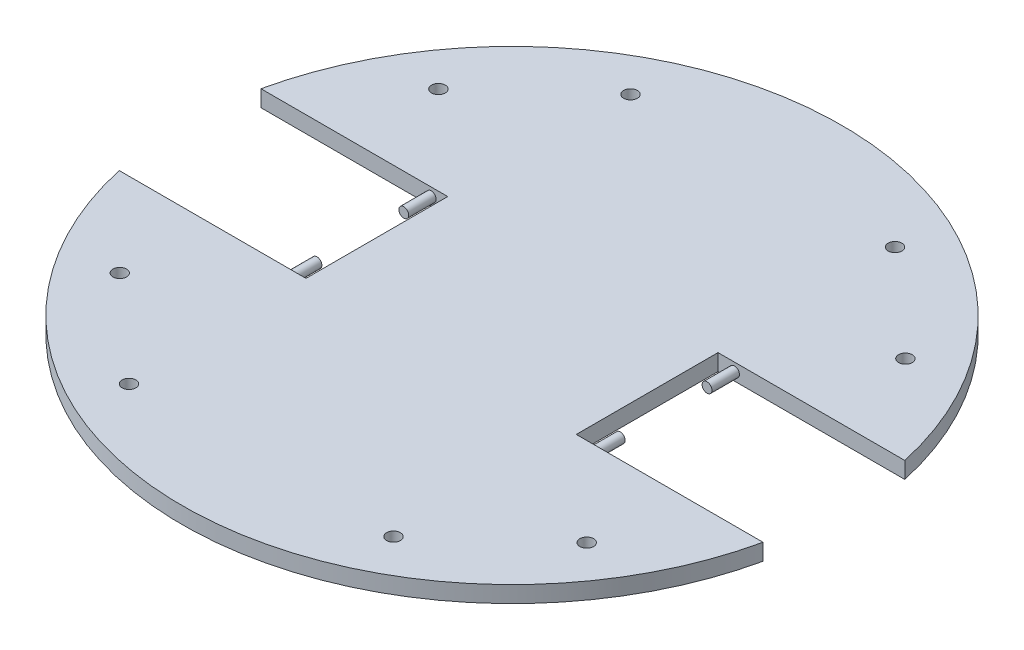
from build123d import *

# Parameters (mm, degrees)
SKETCH1_R           = 60
BOSS_EXTRUDE1_DEPTH = 3
SKETCH2_R           = 1.25
CUT_EXTRUDE1_DEPTH  = 4
CUT_EXTRUDE9_DEPTH  = 4
SKETCH5_R           = 0.9
BOSS_EXTRUDE2_DEPTH = 5
SKETCH7_R           = 0.9
BOSS_EXTRUDE3_DEPTH = 5
SKETCH8_R           = 0.9
BOSS_EXTRUDE4_DEPTH = 5
SKETCH9_R           = 0.9
BOSS_EXTRUDE5_DEPTH = 5


with BuildPart() as part:
    # Sketch1 → Boss-Extrude1 (new body)
    with BuildSketch(Plane(origin=(0, 0, 0), x_dir=(1, 0, 0), z_dir=(0, 1, 0))):
        Circle(SKETCH1_R)
    extrude(amount=BOSS_EXTRUDE1_DEPTH)

    # Sketch2 → Cut-Extrude1 (cut, through all)
    with BuildSketch(Plane(origin=(0, 3, 0), x_dir=(1, 0, 0), z_dir=(0, 1, 0))):
        with Locations((-42.393550358, 29.002085895)):
            Circle(SKETCH2_R)
        with Locations((42.606449642, 29.002085895)):
            Circle(SKETCH2_R)
        with Locations((42.606449642, -29.002085895)):
            Circle(SKETCH2_R)
        with Locations((-42.393550358, -29.002085895)):
            Circle(SKETCH2_R)
        with Locations((-24.073102507, 45.644631202)):
            Circle(SKETCH2_R)
        with Locations((24.073102507, 45.644631202)):
            Circle(SKETCH2_R)
        with Locations((24.073102507, -45.644631202)):
            Circle(SKETCH2_R)
        with Locations((-24.073102507, -45.644631202)):
            Circle(SKETCH2_R)
    extrude(amount=-CUT_EXTRUDE1_DEPTH, mode=Mode.SUBTRACT)

    # Sketch4 → Cut-Extrude9 (cut, through all)
    with BuildSketch(Plane(origin=(0, 3, 0), x_dir=(1, 0, 0), z_dir=(0, 1, 0))):
        with BuildLine():
            Line((-24.6, 12.9), (-58.596842918, 12.9))
            ThreePointArc((-58.596842918, 12.9), (-60, 0), (-58.596842918, -12.9))
            Line((-58.596842918, -12.9), (-24.6, -12.9))
            Line((-24.6, -12.9), (-24.6, 12.9))
        make_face()
        with BuildLine():
            Line((58.596842918, 12.9), (24.6, 12.9))
            Line((24.6, 12.9), (24.6, 0))
            Line((24.6, 0), (60, 0))
            ThreePointArc((60, 0), (59.648179248, 6.488043808), (58.596842918, 12.9))
        make_face()
        with BuildLine():
            Line((60, 0), (24.6, 0))
            Line((24.6, 0), (24.6, -12.9))
            Line((24.6, -12.9), (58.596842918, -12.9))
            ThreePointArc((58.596842918, -12.9), (59.648179248, -6.488043808), (60, 0))
        make_face()
    extrude(amount=-CUT_EXTRUDE9_DEPTH, mode=Mode.SUBTRACT)

    # Sketch5 → Boss-Extrude2 (add)
    with BuildSketch(Plane.XY.offset(-12.9)):
        with Locations((27.6, 1.5)):
            Circle(SKETCH5_R)
    extrude(amount=BOSS_EXTRUDE2_DEPTH)

    # Sketch7 → Boss-Extrude3 (add)
    with BuildSketch(Plane(origin=(0, 0, 12.9), x_dir=(-1, 0, 0), z_dir=(0, 0, -1))):
        with Locations((-27.6, 1.5)):
            Circle(SKETCH7_R)
    extrude(amount=BOSS_EXTRUDE3_DEPTH)

    # Sketch8 → Boss-Extrude4 (add)
    with BuildSketch(Plane.XY.offset(-12.9)):
        with Locations((-27.6, 1.5)):
            Circle(SKETCH8_R)
    extrude(amount=BOSS_EXTRUDE4_DEPTH)

    # Sketch9 → Boss-Extrude5 (add)
    with BuildSketch(Plane(origin=(0, 0, 12.9), x_dir=(-1, 0, 0), z_dir=(0, 0, -1))):
        with Locations((27.6, 1.5)):
            Circle(SKETCH9_R)
    extrude(amount=BOSS_EXTRUDE5_DEPTH)


solid = part.part
